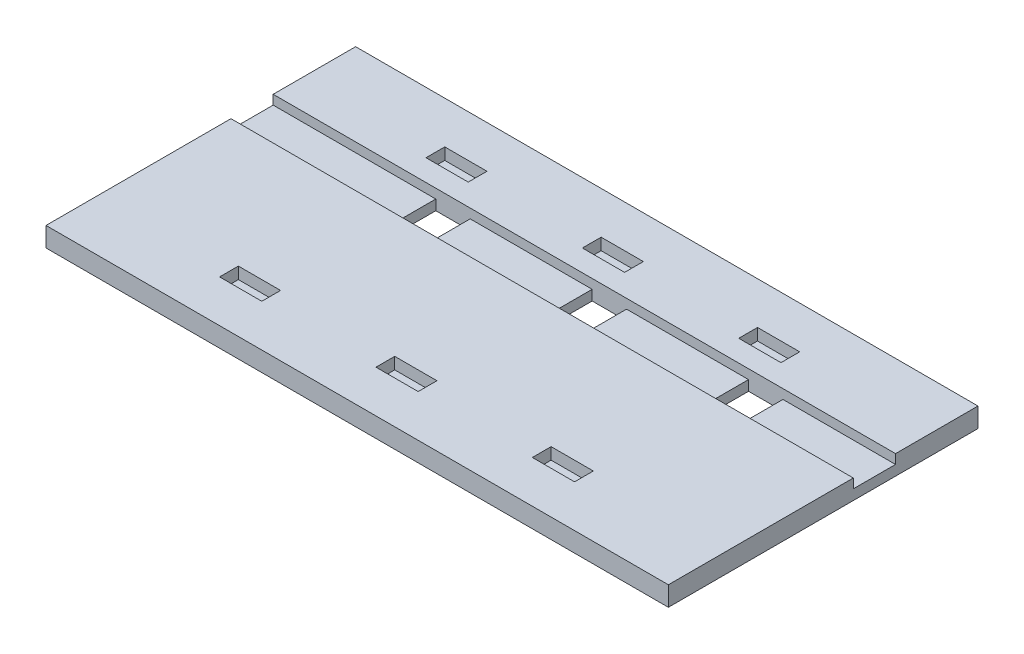
from build123d import *

# Parameters (mm, degrees)
SKETCH1_W                     = 101.092
SKETCH1_H                     = 50.292
BOSS_EXTRUDE1_DEPTH           = 3.175
SKETCH2_W                     = 5.588
SKETCH2_H                     = 6.858
WIRE_HOLE_DEPTH               = 4.175
SKETCH3_W                     = 6.858
SKETCH3_H                     = 3.048
CUT_EXTRUDE2_DEPTH            = 1.905
LPATTERN1_COUNT               = 2
LPATTERN1_PITCH               = 25.4
LPATTERN1_COPY_1_SKETCH_W     = 6.858
LPATTERN1_COPY_1_SKETCH_H     = 3.048
LPATTERN1_COPY_1_DEPTH        = 1.905
LPATTERN1_COL_COUNT           = 2
LPATTERN1_COL_PITCH           = 25.4
LPATTERN1_COL_COPY_1_SKETCH_W = 6.858
LPATTERN1_COL_COPY_1_SKETCH_H = 3.048
LPATTERN1_COL_COPY_1_DEPTH    = 1.905
SKETCH4_W                     = 101.092
SKETCH4_H                     = 6.858
CUT_EXTRUDE3_DEPTH            = 1.524


with BuildPart() as part:
    # Sketch1 → Boss-Extrude1 (new body)
    with BuildSketch(Plane(origin=(0, 0, 0), x_dir=(1, 0, 0), z_dir=(0, 1, 0))):
        Rectangle(SKETCH1_W, SKETCH1_H)
    extrude(amount=BOSS_EXTRUDE1_DEPTH)

    # Sketch2 → Wire Hole (cut, through all)
    with BuildSketch(Plane(origin=(0, 3.175, 0), x_dir=(1, 0, 0), z_dir=(0, 1, 0))):
        with Locations((4.064, 8.322545685)):
            Rectangle(SKETCH2_W, SKETCH2_H)
    wire_hole = extrude(amount=-WIRE_HOLE_DEPTH, mode=Mode.SUBTRACT)

    # Sketch3 → Cut-Extrude2 (cut)
    with BuildSketch(Plane(origin=(0, 3.175, 0), x_dir=(1, 0, 0), z_dir=(0, 1, 0))):
        with Locations((-0.381, 16.764)):
            Rectangle(SKETCH3_W, SKETCH3_H)
    cut_extrude2 = extrude(amount=-CUT_EXTRUDE2_DEPTH, mode=Mode.SUBTRACT)

    # Mirror1: Cut-Extrude2 across plane
    add(cut_extrude2.mirror(Plane.XY), mode=Mode.SUBTRACT)

    # LPattern1: Wire Hole, Cut-Extrude2 ×2
    with Locations(*[(-i * LPATTERN1_PITCH, 0, 0) for i in range(1, LPATTERN1_COUNT)]):
        add(wire_hole, mode=Mode.SUBTRACT)
        add(cut_extrude2, mode=Mode.SUBTRACT)

    # LPattern1 copy 1 sketch → LPattern1 copy 1 (cut)
    with BuildSketch(Plane(origin=(-25.4, 3.175, 0), x_dir=(1, 0, 0), z_dir=(0, 1, 0))):
        with Locations((-0.381, -16.764)):
            Rectangle(LPATTERN1_COPY_1_SKETCH_W, LPATTERN1_COPY_1_SKETCH_H)
    extrude(amount=-LPATTERN1_COPY_1_DEPTH, mode=Mode.SUBTRACT)

    # LPattern1 col: Wire Hole, Cut-Extrude2 ×2
    with Locations(*[(i * LPATTERN1_COL_PITCH, 0, 0) for i in range(1, LPATTERN1_COL_COUNT)]):
        add(wire_hole, mode=Mode.SUBTRACT)
        add(cut_extrude2, mode=Mode.SUBTRACT)

    # LPattern1 col copy 1 sketch → LPattern1 col copy 1 (cut)
    with BuildSketch(Plane(origin=(25.4, 3.175, 0), x_dir=(1, 0, 0), z_dir=(0, 1, 0))):
        with Locations((-0.381, -16.764)):
            Rectangle(LPATTERN1_COL_COPY_1_SKETCH_W, LPATTERN1_COL_COPY_1_SKETCH_H)
    extrude(amount=-LPATTERN1_COL_COPY_1_DEPTH, mode=Mode.SUBTRACT)

    # Sketch4 → Cut-Extrude3 (cut)
    with BuildSketch(Plane(origin=(0, 3.175, 0), x_dir=(1, 0, 0), z_dir=(0, 1, 0))):
        with Locations((0, 8.322545685)):
            Rectangle(SKETCH4_W, SKETCH4_H)
    extrude(amount=-CUT_EXTRUDE3_DEPTH, mode=Mode.SUBTRACT)


solid = part.part
